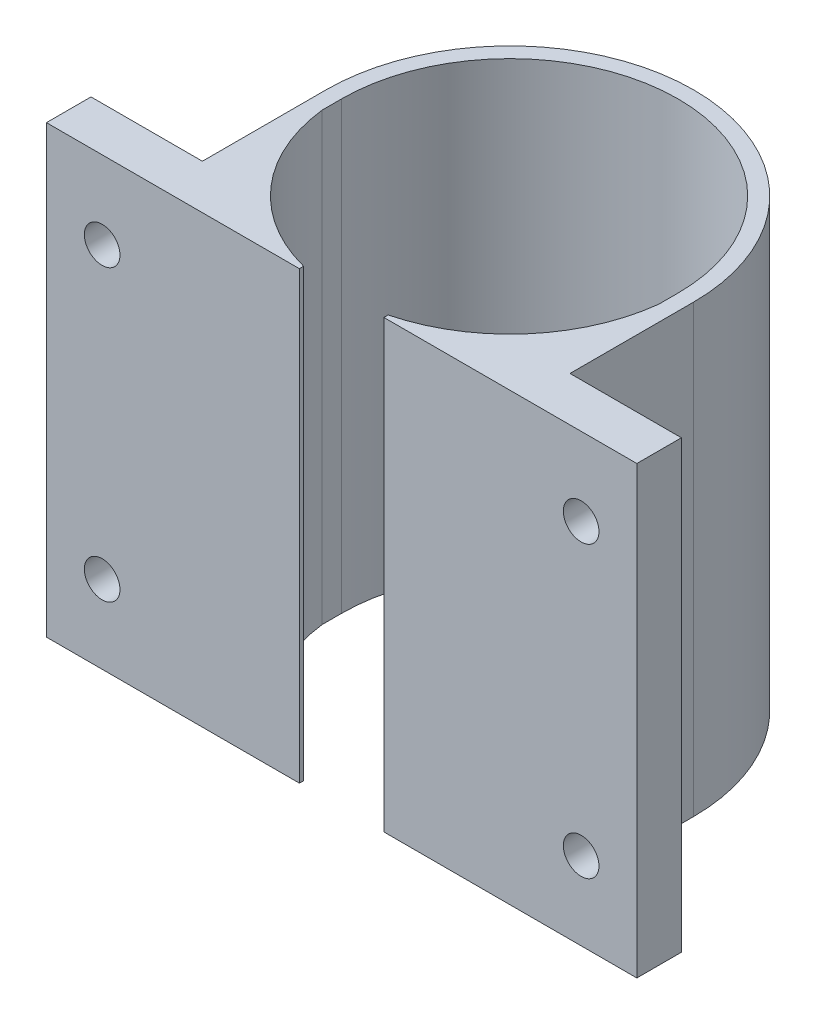
from build123d import *

# Parameters (mm, degrees)
BOSS_EXTRUDE3_DEPTH = 40
SKETCH8_W           = 4
SKETCH8_H           = 40
BOSS_EXTRUDE6_DEPTH = 10
SKETCH9_W           = 4
SKETCH9_H           = 40
BOSS_EXTRUDE7_DEPTH = 10
BOSS_EXTRUDE9_DEPTH = 40
CUT_EXTRUDE1_DEPTH  = 40
SCALE1_SCALE_X      = 0.8
SCALE1_SCALE_Y      = 0.8
SCALE1_SCALE_Z      = 0.8


with BuildPart() as part:
    # Sketch3 → Boss-Extrude3 (new body)
    with BuildSketch(Plane(origin=(0, 0, 0), x_dir=(1, 0, 0), z_dir=(0, 1, 0))):
        with BuildLine():
            ThreePointArc((16.5, 0), (0, 16.5), (-16.5, 0))
            Line((-16.5, 0), (-16.5, -15.1))
            Line((-16.5, -15.1), (-15.1, -15.1))
            Line((-15.1, -15.1), (-15.1, 0))
            ThreePointArc((-15.1, 0), (0, 15.1), (15.1, 0))
            Line((15.1, 0), (15.1, -15.1))
            Line((15.1, -15.1), (16.5, -15.1))
            Line((16.5, -15.1), (16.5, 0))
        make_face()
    extrude(amount=BOSS_EXTRUDE3_DEPTH)

    # Sketch8 → Boss-Extrude6 (add)
    with BuildSketch(Plane(origin=(16.5, 0, 0), x_dir=(0, 0, -1), z_dir=(1, 0, 0))):
        with Locations((-13.1, 20)):
            Rectangle(SKETCH8_W, SKETCH8_H)
    extrude(amount=BOSS_EXTRUDE6_DEPTH)

    # Sketch9 → Boss-Extrude7 (add)
    with BuildSketch(Plane.ZY.offset(16.5)):
        with Locations((13.1, 20)):
            Rectangle(SKETCH9_W, SKETCH9_H)
    extrude(amount=BOSS_EXTRUDE7_DEPTH)

    # Sketch10 → Boss-Extrude9 (add)
    with BuildSketch(Plane(origin=(0, 0, 0), x_dir=(-1, 0, 0), z_dir=(0, -1, 0))):
        with BuildLine():
            Line((3.791332709, -15.1), (15.1, -15.1))
            Line((15.1, -15.1), (15.1, -1.740689519))
            ThreePointArc((15.1, -1.740689519), (11.460081139, -9.985316234), (3.791332709, -14.719571879))
            Line((3.791332709, -14.719571879), (3.791332709, -15.1))
        make_face()
        with BuildLine():
            Line((-15.1, -15.1), (-3.791332709, -15.1))
            Line((-3.791332709, -15.1), (-3.791332709, -14.719571879))
            ThreePointArc((-3.791332709, -14.719571879), (-11.460081139, -9.985316234), (-15.1, -1.740689519))
            Line((-15.1, -1.740689519), (-15.1, -15.1))
        make_face()
    extrude(amount=-BOSS_EXTRUDE9_DEPTH)

    # Sketch11 → Cut-Extrude1 (cut)
    with BuildSketch(Plane(origin=(0, 0, 11.1), x_dir=(-1, 0, 0), z_dir=(0, 0, -1))):
        with BuildLine():
            ThreePointArc((-19.9, 33), (-20.36862915, 34.13137085), (-21.5, 34.6))
            Line((-21.5, 34.6), (-21.5, 31.4))
            ThreePointArc((-21.5, 31.4), (-20.36862915, 31.86862915), (-19.9, 33))
        make_face()
        with BuildLine():
            Line((-21.5, 31.4), (-21.5, 34.6))
            ThreePointArc((-21.5, 34.6), (-23.1, 33), (-21.5, 31.4))
        make_face()
        with BuildLine():
            ThreePointArc((-19.9, 7), (-20.36862915, 8.13137085), (-21.5, 8.6))
            Line((-21.5, 8.6), (-21.5, 5.4))
            ThreePointArc((-21.5, 5.4), (-20.36862915, 5.86862915), (-19.9, 7))
        make_face()
        with BuildLine():
            Line((-21.5, 5.4), (-21.5, 8.6))
            ThreePointArc((-21.5, 8.6), (-23.1, 7), (-21.5, 5.4))
        make_face()
        with BuildLine():
            ThreePointArc((23.1, 7), (22.63137085, 8.13137085), (21.5, 8.6))
            Line((21.5, 8.6), (21.5, 5.4))
            ThreePointArc((21.5, 5.4), (22.63137085, 5.86862915), (23.1, 7))
        make_face()
        with BuildLine():
            Line((21.5, 5.4), (21.5, 8.6))
            ThreePointArc((21.5, 8.6), (19.9, 7), (21.5, 5.4))
        make_face()
        with BuildLine():
            ThreePointArc((23.1, 33), (22.63137085, 34.13137085), (21.5, 34.6))
            Line((21.5, 34.6), (21.5, 31.4))
            ThreePointArc((21.5, 31.4), (22.63137085, 31.86862915), (23.1, 33))
        make_face()
        with BuildLine():
            Line((21.5, 31.4), (21.5, 34.6))
            ThreePointArc((21.5, 34.6), (19.9, 33), (21.5, 31.4))
        make_face()
    extrude(amount=-CUT_EXTRUDE1_DEPTH, mode=Mode.SUBTRACT)


with BuildPart() as part_1:
    # Scale1: scaled about (0, 0, 0)
    add(part.part.scale((SCALE1_SCALE_X, SCALE1_SCALE_Y, SCALE1_SCALE_Z), about=(0, 0, 0)))


solid = part_1.part
